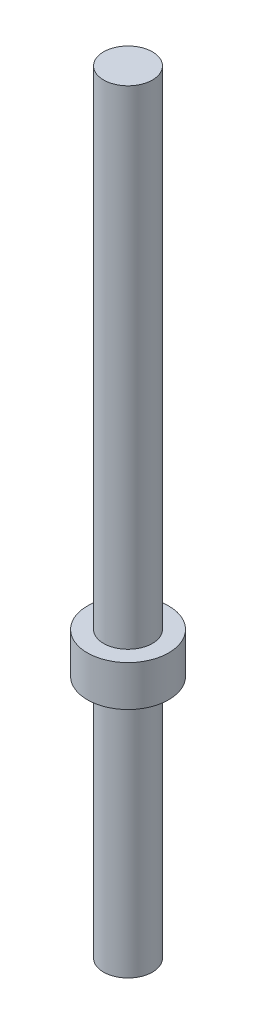
from build123d import *

# Parameters (mm, degrees)
SKETCH2_R           = 0.3
BASE_EXTRUDE_DEPTH  = 6.5
SKETCH3_R           = 0.5
BOSS_EXTRUDE1_DEPTH = 0.5
SKETCH4_R           = 0.3
BOSS_EXTRUDE2_DEPTH = 3


with BuildPart() as part:
    # Sketch2 → Base-Extrude (new body)
    with BuildSketch(Plane(origin=(0, 0, 0), x_dir=(1, 0, 0), z_dir=(0, 1, 0))):
        Circle(SKETCH2_R)
    extrude(amount=BASE_EXTRUDE_DEPTH)

    # Sketch3 → Boss-Extrude1 (add)
    with BuildSketch(Plane.XZ):
        Circle(SKETCH3_R)
    extrude(amount=-BOSS_EXTRUDE1_DEPTH)

    # Sketch4 → Boss-Extrude2 (add)
    with BuildSketch(Plane.XZ):
        Circle(SKETCH4_R)
    extrude(amount=BOSS_EXTRUDE2_DEPTH)


solid = part.part
